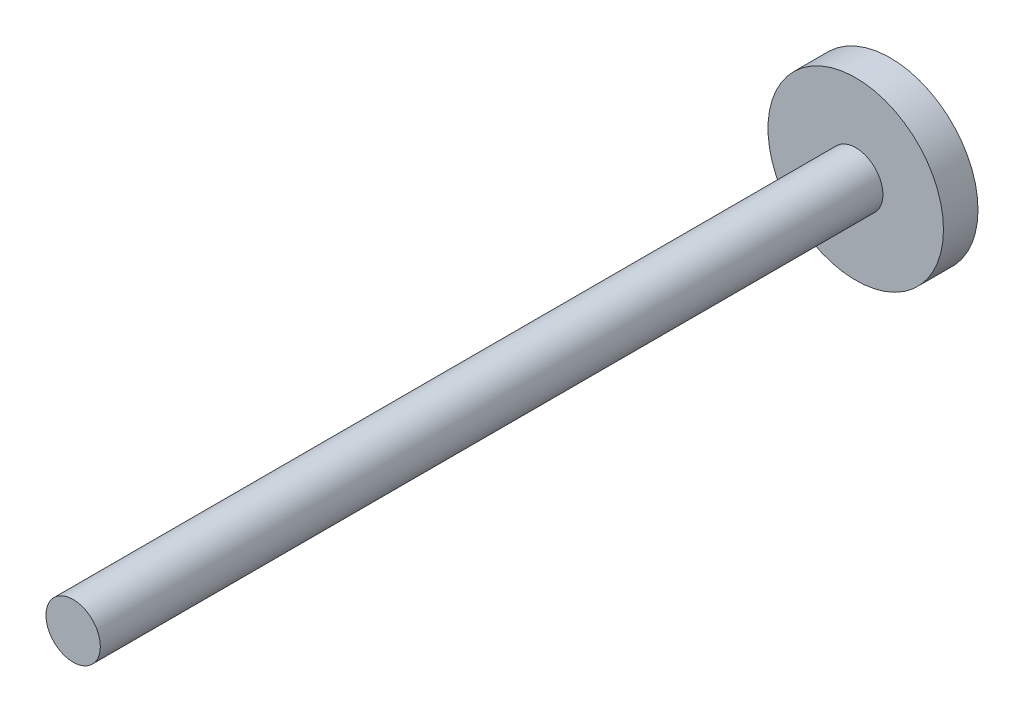
from build123d import *

# Parameters (mm, degrees)
SKETCH1_R           = 12.7
BOSS_EXTRUDE1_DEPTH = 5
SKETCH2_R           = 3.937
BOSS_EXTRUDE3_DEPTH = 113.284


with BuildPart() as part:
    # Sketch1 → Boss-Extrude1 (new body)
    with BuildSketch(Plane.XY):
        Circle(SKETCH1_R)
    extrude(amount=BOSS_EXTRUDE1_DEPTH)

    # Sketch2 → Boss-Extrude3 (add)
    with BuildSketch(Plane.XY.offset(5)):
        Circle(SKETCH2_R)
    extrude(amount=BOSS_EXTRUDE3_DEPTH)


solid = part.part
